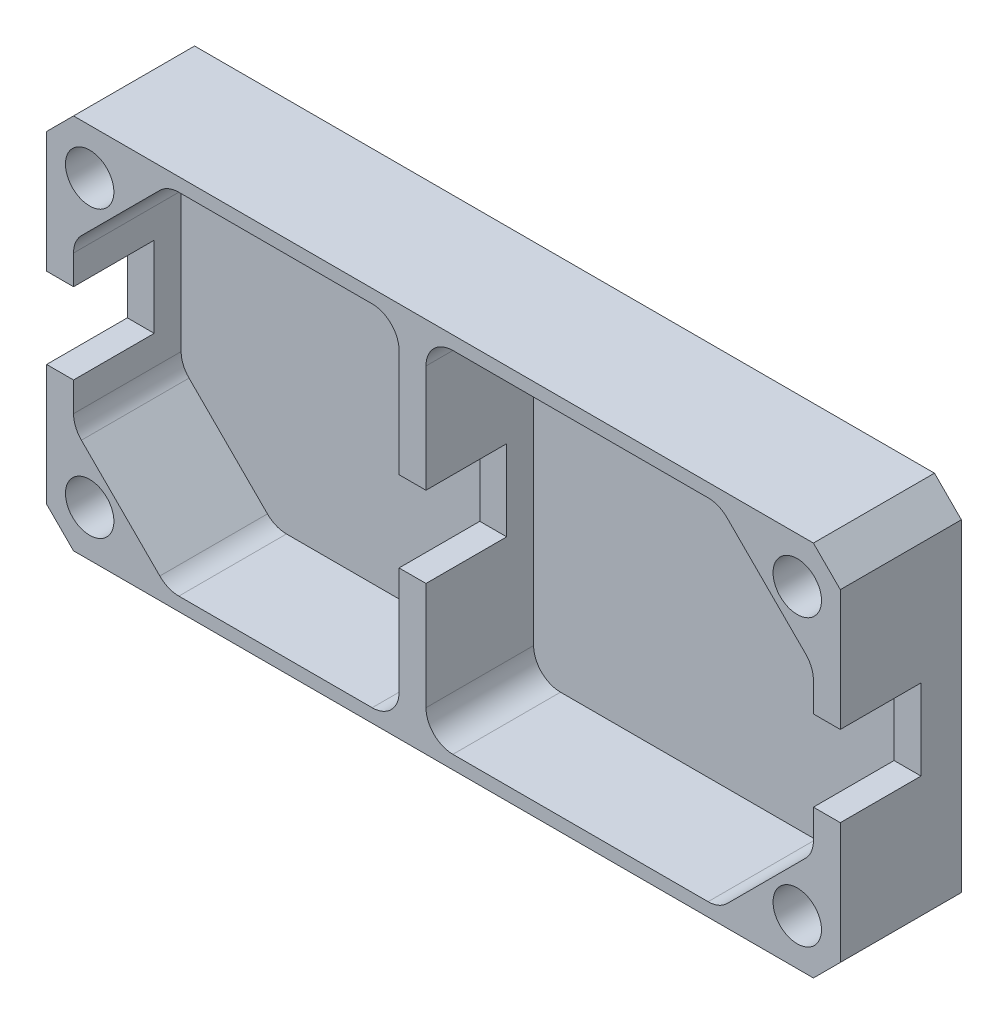
from build123d import *

# Parameters (mm, degrees)
SKETCH_1_W              = 29.5
SKETCH_1_H              = 14
EXTRUDE_1_DEPTH         = 4.5
CUT_EXTRUDE_1_DEPTH     = 4
CHAMFER_1_SIZE          = 1
HOLE_WIZARD_M1_61_D     = 1.8
HOLE_WIZARD_M1_61_DEPTH = 14
HOLE_WIZARD_M1_61_TIP   = 0.540774557
FILLET_1_R              = 1
SKETCH_5_W              = 29.5
SKETCH_5_H              = 3
CUT_EXTRUDE_2_DEPTH     = 3
CHAMFER_2_SIZE          = 0.6
CUT_EXTRUDE_3_DEPTH     = 0.01


with BuildPart() as part:
    # Эскиз1 → Бобышка-Вытянуть1 (new body)
    with BuildSketch(Plane.XY):
        Rectangle(SKETCH_1_W, SKETCH_1_H)
    extrude(amount=EXTRUDE_1_DEPTH)

    # Эскиз2 → Вырез-Вытянуть1 (cut)
    with BuildSketch(Plane.XY.offset(4.5)):
        Polygon((-10.25, 6.5), (-1.65, 6.5), (-1.65, -6.5), (-10.25, -6.5), (-13.75, -3), (-13.75, 3), align=None)
        Polygon((-0.65, 6.5), (10.25, 6.5), (13.75, 3), (13.75, -3), (10.25, -6.5), (-0.65, -6.5), align=None)
    extrude(amount=-CUT_EXTRUDE_1_DEPTH, mode=Mode.SUBTRACT)

    # Фаска1
    chamfer_1_edges = [part.edges().sort_by_distance(p)[0] for p in [
        (14.75, -7, 2.25),
        (-14.75, -7, 2.25),
        (-14.75, 7, 2.25),
        (14.75, 7, 2.25),
    ]]
    chamfer(chamfer_1_edges, length=CHAMFER_1_SIZE)

    # Отверстие с зазором M1,61
    with Locations(Plane.XY.offset(4.5)):
        with Locations((-13.15, 5.3), (13.15, 5.3), (-13.15, -5.3), (13.15, -5.3)):
            Hole(HOLE_WIZARD_M1_61_D / 2, depth=HOLE_WIZARD_M1_61_DEPTH)
            with Locations((0, 0, -(HOLE_WIZARD_M1_61_DEPTH + HOLE_WIZARD_M1_61_TIP / 2))):  # 118° drill point
                Cone(0, HOLE_WIZARD_M1_61_D / 2, HOLE_WIZARD_M1_61_TIP, mode=Mode.SUBTRACT)

    # Скругление1
    fillet_1_edges = [part.edges().sort_by_distance(p)[0] for p in [
        (10.25, 6.5, 2.5),
        (13.75, 3, 2.5),
        (13.75, -3, 2.5),
        (10.25, -6.5, 2.5),
        (-0.65, -6.5, 2.5),
        (-0.65, 6.5, 2.5),
        (-13.75, 3, 2.5),
        (-10.25, 6.5, 2.5),
        (-1.65, 6.5, 2.5),
        (-1.65, -6.5, 2.5),
        (-10.25, -6.5, 2.5),
        (-13.75, -3, 2.5),
    ]]
    fillet(fillet_1_edges, radius=FILLET_1_R)

    # Эскиз5 → Вырез-Вытянуть2 (cut)
    with BuildSketch(Plane.XY.offset(4.5)):
        Rectangle(SKETCH_5_W, SKETCH_5_H)
    extrude(amount=-CUT_EXTRUDE_2_DEPTH, mode=Mode.SUBTRACT)

    # Фаска2
    chamfer_2_edges = [part.edges().sort_by_distance(p)[0] for p in [
        (14.05, -5.3, 0),
        (-12.25, -5.3, 0),
        (14.05, 5.3, 0),
        (-12.25, 5.3, 0),
    ]]
    chamfer(chamfer_2_edges, length=CHAMFER_2_SIZE)

    # Эскиз6 → Вырез-Вытянуть3 (cut)
    with BuildSketch(Plane(origin=(0, 0, 0), x_dir=(-1, 0, 0), z_dir=(0, 0, -1))):
        Polygon((-13.25, 0), (-9.75, 0.617144432), (-9.75, -0.617144432), align=None)
    extrude(amount=-CUT_EXTRUDE_3_DEPTH, mode=Mode.SUBTRACT)


solid = part.part
